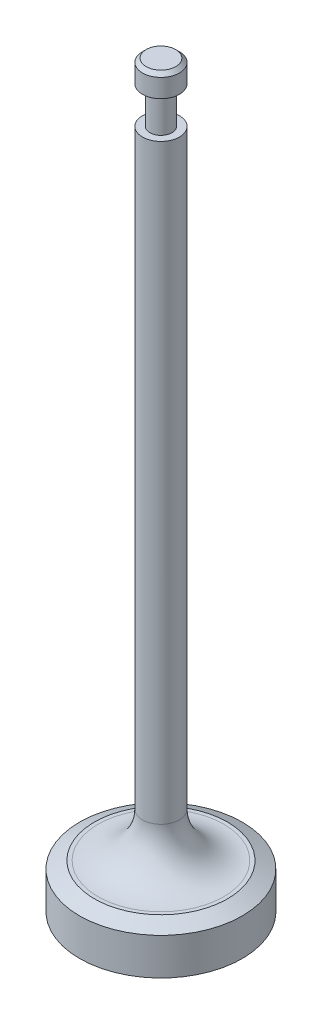
from build123d import *

# Parameters (mm, degrees)
FILLET1_R      = 6
CHAMFER1_SIZE  = 1
CHAMFER1_SIZE2 = 2
CHAMFER3_SIZE  = 0.5


with BuildPart() as part:
    # Sketch1 → Revolve1 (revolve)
    with BuildSketch(Plane(origin=(0, 0, 0), x_dir=(0, 0, -1), z_dir=(1, 0, 0))):
        Polygon((0, 0), (0, -100), (11, -100), (11, -94), (2.5, -94), (2.5, -8), (1.5, -8), (1.5, -3), (2.5, -3), (2.5, 0), align=None)
    revolve(axis=Axis((0, 0, 0), (0, -1, 0)))

    # Fillet1
    fillet1_edges = [part.edges().sort_by_distance(p)[0] for p in [
        (0, -94, 2.5),
    ]]
    fillet(fillet1_edges, radius=FILLET1_R)

    # Chamfer1
    chamfer1_edges = [part.edges().sort_by_distance(p)[0] for p in [
        (0, -94, 11),
    ]]
    chamfer1_side = [part.faces().sort_by_distance(p)[0] for p in [
        (0, -97, 11),
    ]]
    chamfer(chamfer1_edges, length=CHAMFER1_SIZE, length2=CHAMFER1_SIZE2, reference=chamfer1_side[0])

    # Chamfer3
    chamfer3_edges = [part.edges().sort_by_distance(p)[0] for p in [
        (0, 0, 2.5),
    ]]
    chamfer(chamfer3_edges, length=CHAMFER3_SIZE)


solid = part.part
